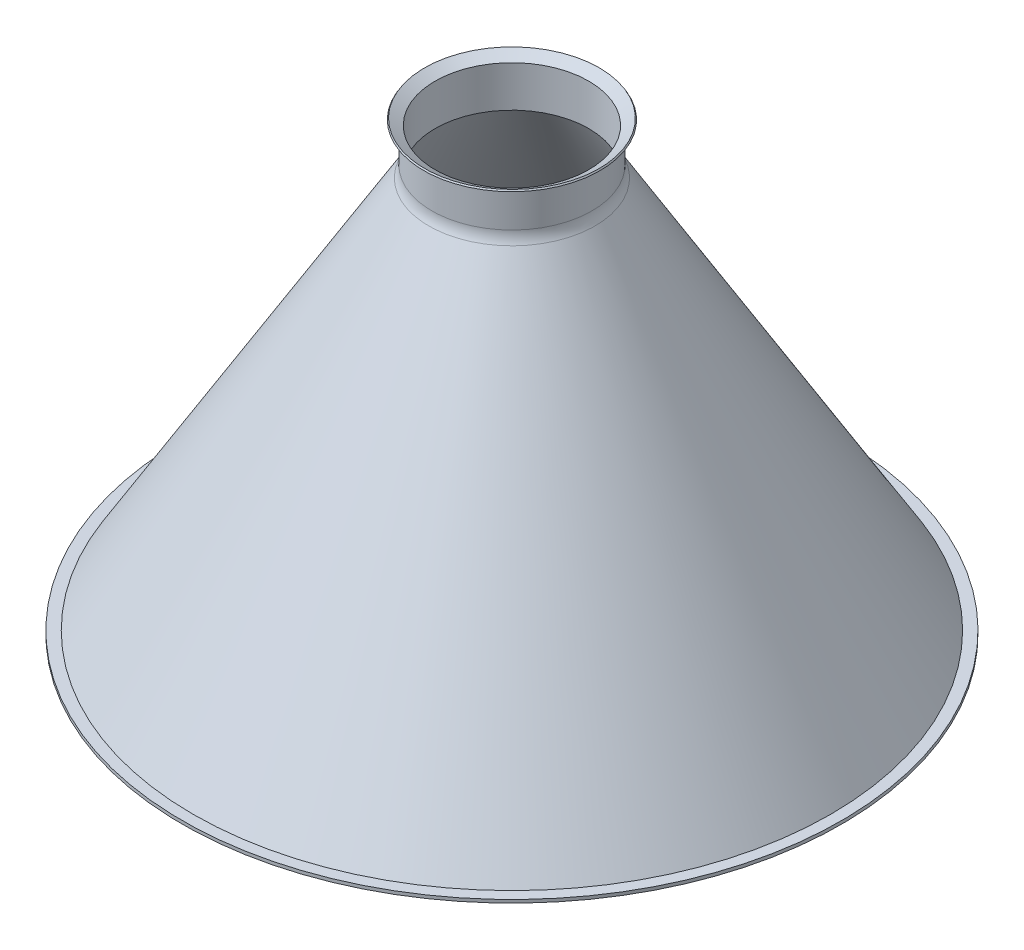
from build123d import *

# Parameters (mm, degrees)
FILLET1_R = 7


with BuildPart() as part:
    # Sketch1 → Revolve1 (revolve)
    with BuildSketch(Plane.XY):
        Polygon((25.26151891, 74.539497083), (25.26151891, 61.839497083), (100.628081163, -63.543576688), (104.062419804, -63.543576688), (104.062419804, -64.543576688), (100.062419804, -64.543576688), (24.26151891, 61.562081639), (24.26151891, 74.539497083), (27.567346656, 76.526598412), (27.832759941, 76.085045388), align=None)
    revolve(axis=Axis((0, 0, 0), (0, 1, 0)))

    # Fillet1
    fillet1_edges = [part.edges().sort_by_distance(p)[0] for p in [
        (-25.26151891, 61.839497083, 0),
    ]]
    fillet(fillet1_edges, radius=FILLET1_R)


solid = part.part
